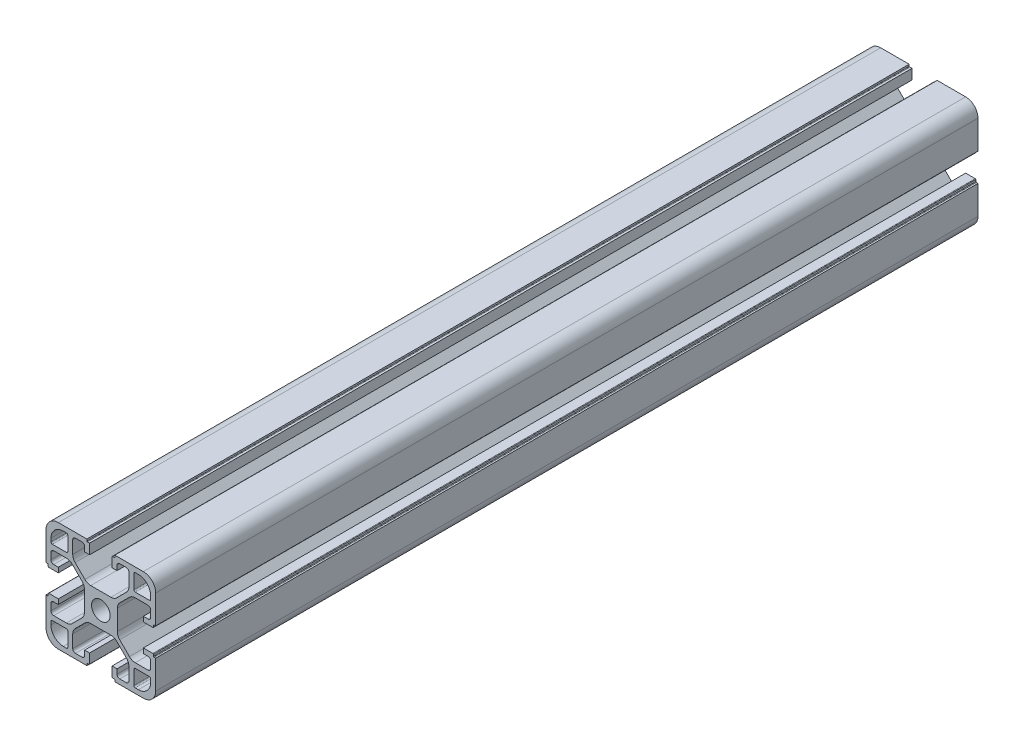
from build123d import *

# Parameters (mm, degrees)
BOSS_EXTRUDE1_DEPTH = 300


with BuildPart() as part:
    # Sketch1 → Boss-Extrude1 (new body)
    with BuildSketch(Plane.XY):
        with BuildLine():
            Line((84.170223908, 31.720417041), (84.170223908, 42.120417041))
            Line((84.170223908, 42.120417041), (83.570223908, 42.120417041))
            ThreePointArc((83.570223908, 42.120417041), (83.428802552, 42.178995685), (83.370223908, 42.320417041))
            Line((83.370223908, 42.320417041), (83.370223908, 42.920417041))
            ThreePointArc((83.370223908, 42.920417041), (83.311645264, 43.061838398), (83.170223908, 43.120417041))
            Line((83.170223908, 43.120417041), (79.670223908, 43.120417041))
            Line((79.670223908, 43.120417041), (79.670223908, 41.320417041))
            Line((79.670223908, 41.320417041), (81.370223908, 41.320417041))
            ThreePointArc((81.370223908, 41.320417041), (82.077330689, 41.027523823), (82.370223908, 40.320417041))
            Line((82.370223908, 40.320417041), (82.370223908, 37.970417041))
            ThreePointArc((82.370223908, 37.970417041), (82.077330689, 37.26331026), (81.370223908, 36.970417041))
            Line((81.370223908, 36.970417041), (76.723524767, 36.970417041))
            ThreePointArc((76.723524767, 36.970417041), (75.57547447, 37.198778444), (74.602204423, 37.849096698))
            Line((74.602204423, 37.849096698), (71.048903564, 41.402397557))
            ThreePointArc((71.048903564, 41.402397557), (70.39858531, 42.375667603), (70.170223908, 43.5237179))
            Line((70.170223908, 43.5237179), (70.170223908, 50.917116183))
            ThreePointArc((70.170223908, 50.917116183), (70.39858531, 52.06516648), (71.048903564, 53.038436526))
            Line((71.048903564, 53.038436526), (74.602204423, 56.591737385))
            ThreePointArc((74.602204423, 56.591737385), (75.57547447, 57.242055639), (76.723524767, 57.470417041))
            Line((76.723524767, 57.470417041), (81.370223908, 57.470417041))
            ThreePointArc((81.370223908, 57.470417041), (82.077330689, 57.177523823), (82.370223908, 56.470417041))
            Line((82.370223908, 56.470417041), (82.370223908, 54.120417041))
            ThreePointArc((82.370223908, 54.120417041), (82.077330689, 53.41331026), (81.370223908, 53.120417041))
            Line((81.370223908, 53.120417041), (79.670223908, 53.120417041))
            Line((79.670223908, 53.120417041), (79.670223908, 51.320417041))
            Line((79.670223908, 51.320417041), (83.170223908, 51.320417041))
            ThreePointArc((83.170223908, 51.320417041), (83.311645264, 51.378995685), (83.370223908, 51.520417041))
            Line((83.370223908, 51.520417041), (83.370223908, 52.120417041))
            ThreePointArc((83.370223908, 52.120417041), (83.428802552, 52.261838398), (83.570223908, 52.320417041))
            Line((83.570223908, 52.320417041), (84.170223908, 52.320417041))
            Line((84.170223908, 52.320417041), (84.170223908, 62.720417041))
            ThreePointArc((84.170223908, 62.720417041), (82.852204423, 65.902397557), (79.670223908, 67.220417041))
            Line((79.670223908, 67.220417041), (69.270223908, 67.220417041))
            Line((69.270223908, 67.220417041), (69.270223908, 66.420417041))
            Line((69.270223908, 66.420417041), (68.470223908, 66.420417041))
            ThreePointArc((68.470223908, 66.420417041), (68.328802552, 66.361838398), (68.270223908, 66.220417041))
            Line((68.270223908, 66.220417041), (68.270223908, 62.720417041))
            Line((68.270223908, 62.720417041), (70.070223908, 62.720417041))
            Line((70.070223908, 62.720417041), (70.070223908, 64.420417041))
            ThreePointArc((70.070223908, 64.420417041), (70.363117127, 65.127523823), (71.070223908, 65.420417041))
            Line((71.070223908, 65.420417041), (73.420223908, 65.420417041))
            ThreePointArc((73.420223908, 65.420417041), (74.127330689, 65.127523823), (74.420223908, 64.420417041))
            Line((74.420223908, 64.420417041), (74.420223908, 59.7737179))
            ThreePointArc((74.420223908, 59.7737179), (74.191862505, 58.625667603), (73.541544251, 57.652397557))
            Line((73.541544251, 57.652397557), (69.988243393, 54.099096698))
            ThreePointArc((69.988243393, 54.099096698), (69.014973346, 53.448778444), (67.866923049, 53.220417041))
            Line((67.866923049, 53.220417041), (60.473524767, 53.220417041))
            ThreePointArc((60.473524767, 53.220417041), (59.32547447, 53.448778444), (58.352204423, 54.099096698))
            Line((58.352204423, 54.099096698), (54.798903564, 57.652397557))
            ThreePointArc((54.798903564, 57.652397557), (54.14858531, 58.625667603), (53.920223908, 59.7737179))
            Line((53.920223908, 59.7737179), (53.920223908, 64.420417041))
            ThreePointArc((53.920223908, 64.420417041), (54.213117127, 65.127523823), (54.920223908, 65.420417041))
            Line((54.920223908, 65.420417041), (57.270223908, 65.420417041))
            ThreePointArc((57.270223908, 65.420417041), (57.977330689, 65.127523823), (58.270223908, 64.420417041))
            Line((58.270223908, 64.420417041), (58.270223908, 62.720417041))
            Line((58.270223908, 62.720417041), (60.070223908, 62.720417041))
            Line((60.070223908, 62.720417041), (60.070223908, 66.420417041))
            Line((60.070223908, 66.420417041), (59.270223908, 66.420417041))
            ThreePointArc((59.270223908, 66.420417041), (59.128802552, 66.478995685), (59.070223908, 66.620417041))
            Line((59.070223908, 66.620417041), (59.070223908, 67.220417041))
            Line((59.070223908, 67.220417041), (48.670223908, 67.220417041))
            ThreePointArc((48.670223908, 67.220417041), (45.488243393, 65.902397557), (44.170223908, 62.720417041))
            Line((44.170223908, 62.720417041), (44.170223908, 52.320417041))
            Line((44.170223908, 52.320417041), (44.770223908, 52.320417041))
            ThreePointArc((44.770223908, 52.320417041), (44.911645264, 52.261838398), (44.970223908, 52.120417041))
            Line((44.970223908, 52.120417041), (44.970223908, 51.520417041))
            ThreePointArc((44.970223908, 51.520417041), (45.028802552, 51.378995685), (45.170223908, 51.320417041))
            Line((45.170223908, 51.320417041), (48.670223908, 51.320417041))
            Line((48.670223908, 51.320417041), (48.670223908, 53.120417041))
            Line((48.670223908, 53.120417041), (46.970223908, 53.120417041))
            ThreePointArc((46.970223908, 53.120417041), (46.263117127, 53.41331026), (45.970223908, 54.120417041))
            Line((45.970223908, 54.120417041), (45.970223908, 56.470417041))
            ThreePointArc((45.970223908, 56.470417041), (46.263117127, 57.177523823), (46.970223908, 57.470417041))
            Line((46.970223908, 57.470417041), (51.616923049, 57.470417041))
            ThreePointArc((51.616923049, 57.470417041), (52.764973346, 57.242055639), (53.738243393, 56.591737385))
            Line((53.738243393, 56.591737385), (57.291544251, 53.038436526))
            ThreePointArc((57.291544251, 53.038436526), (57.941862505, 52.06516648), (58.170223908, 50.917116183))
            Line((58.170223908, 50.917116183), (58.170223908, 43.5237179))
            ThreePointArc((58.170223908, 43.5237179), (57.941862505, 42.375667603), (57.291544251, 41.402397557))
            Line((57.291544251, 41.402397557), (53.738243393, 37.849096698))
            ThreePointArc((53.738243393, 37.849096698), (52.764973346, 37.198778444), (51.616923049, 36.970417041))
            Line((51.616923049, 36.970417041), (46.970223908, 36.970417041))
            ThreePointArc((46.970223908, 36.970417041), (46.263117127, 37.26331026), (45.970223908, 37.970417041))
            Line((45.970223908, 37.970417041), (45.970223908, 40.320417041))
            ThreePointArc((45.970223908, 40.320417041), (46.263117127, 41.027523823), (46.970223908, 41.320417041))
            Line((46.970223908, 41.320417041), (48.670223908, 41.320417041))
            Line((48.670223908, 41.320417041), (48.670223908, 43.120417041))
            Line((48.670223908, 43.120417041), (45.170223908, 43.120417041))
            ThreePointArc((45.170223908, 43.120417041), (45.028802552, 43.061838398), (44.970223908, 42.920417041))
            Line((44.970223908, 42.920417041), (44.970223908, 42.320417041))
            ThreePointArc((44.970223908, 42.320417041), (44.911645264, 42.178995685), (44.770223908, 42.120417041))
            Line((44.770223908, 42.120417041), (44.170223908, 42.120417041))
            Line((44.170223908, 42.120417041), (44.170223908, 31.720417041))
            ThreePointArc((44.170223908, 31.720417041), (45.488243393, 28.538436526), (48.670223908, 27.220417041))
            Line((48.670223908, 27.220417041), (59.070223908, 27.220417041))
            Line((59.070223908, 27.220417041), (59.070223908, 27.820417041))
            ThreePointArc((59.070223908, 27.820417041), (59.128802552, 27.961838398), (59.270223908, 28.020417041))
            Line((59.270223908, 28.020417041), (59.870223908, 28.020417041))
            ThreePointArc((59.870223908, 28.020417041), (60.011645264, 28.078995685), (60.070223908, 28.220417041))
            Line((60.070223908, 28.220417041), (60.070223908, 31.720417041))
            Line((60.070223908, 31.720417041), (58.270223908, 31.720417041))
            Line((58.270223908, 31.720417041), (58.270223908, 30.020417041))
            ThreePointArc((58.270223908, 30.020417041), (57.977330689, 29.31331026), (57.270223908, 29.020417041))
            Line((57.270223908, 29.020417041), (54.920223908, 29.020417041))
            ThreePointArc((54.920223908, 29.020417041), (54.213117127, 29.31331026), (53.920223908, 30.020417041))
            Line((53.920223908, 30.020417041), (53.920223908, 34.667116183))
            ThreePointArc((53.920223908, 34.667116183), (54.14858531, 35.81516648), (54.798903564, 36.788436526))
            Line((54.798903564, 36.788436526), (58.352204423, 40.341737385))
            ThreePointArc((58.352204423, 40.341737385), (59.32547447, 40.992055639), (60.473524767, 41.220417041))
            Line((60.473524767, 41.220417041), (67.866923049, 41.220417041))
            ThreePointArc((67.866923049, 41.220417041), (69.014973346, 40.992055639), (69.988243393, 40.341737385))
            Line((69.988243393, 40.341737385), (73.541544251, 36.788436526))
            ThreePointArc((73.541544251, 36.788436526), (74.191862505, 35.81516648), (74.420223908, 34.667116183))
            Line((74.420223908, 34.667116183), (74.420223908, 30.020417041))
            ThreePointArc((74.420223908, 30.020417041), (74.127330689, 29.31331026), (73.420223908, 29.020417041))
            Line((73.420223908, 29.020417041), (71.070223908, 29.020417041))
            ThreePointArc((71.070223908, 29.020417041), (70.363117127, 29.31331026), (70.070223908, 30.020417041))
            Line((70.070223908, 30.020417041), (70.070223908, 31.720417041))
            Line((70.070223908, 31.720417041), (68.270223908, 31.720417041))
            Line((68.270223908, 31.720417041), (68.270223908, 28.220417041))
            ThreePointArc((68.270223908, 28.220417041), (68.328802552, 28.078995685), (68.470223908, 28.020417041))
            Line((68.470223908, 28.020417041), (69.070223908, 28.020417041))
            ThreePointArc((69.070223908, 28.020417041), (69.211645264, 27.961838398), (69.270223908, 27.820417041))
            Line((69.270223908, 27.820417041), (69.270223908, 27.220417041))
            Line((69.270223908, 27.220417041), (79.670223908, 27.220417041))
            ThreePointArc((79.670223908, 27.220417041), (82.852204423, 28.538436526), (84.170223908, 31.720417041))
        make_face()
        with BuildLine():
            Line((82.370223908, 34.670417041), (82.370223908, 33.520417041))
            ThreePointArc((82.370223908, 33.520417041), (81.052204423, 30.338436526), (77.870223908, 29.020417041))
            Line((77.870223908, 29.020417041), (76.720223908, 29.020417041))
            ThreePointArc((76.720223908, 29.020417041), (76.366670517, 29.166863651), (76.220223908, 29.520417041))
            Line((76.220223908, 29.520417041), (76.220223908, 34.670417041))
            ThreePointArc((76.220223908, 34.670417041), (76.366670517, 35.023970432), (76.720223908, 35.170417041))
            Line((76.720223908, 35.170417041), (81.870223908, 35.170417041))
            ThreePointArc((81.870223908, 35.170417041), (82.223777298, 35.023970432), (82.370223908, 34.670417041))
        make_face(mode=Mode.SUBTRACT)
        with BuildLine():
            Line((51.620223908, 29.020417041), (50.470223908, 29.020417041))
            ThreePointArc((50.470223908, 29.020417041), (47.288243393, 30.338436526), (45.970223908, 33.520417041))
            Line((45.970223908, 33.520417041), (45.970223908, 34.670417041))
            ThreePointArc((45.970223908, 34.670417041), (46.116670517, 35.023970432), (46.470223908, 35.170417041))
            Line((46.470223908, 35.170417041), (51.620223908, 35.170417041))
            ThreePointArc((51.620223908, 35.170417041), (51.973777298, 35.023970432), (52.120223908, 34.670417041))
            Line((52.120223908, 34.670417041), (52.120223908, 29.520417041))
            ThreePointArc((52.120223908, 29.520417041), (51.973777298, 29.166863651), (51.620223908, 29.020417041))
        make_face(mode=Mode.SUBTRACT)
        with BuildLine():
            Line((45.970223908, 59.770417041), (45.970223908, 60.920417041))
            ThreePointArc((45.970223908, 60.920417041), (47.288243393, 64.102397557), (50.470223908, 65.420417041))
            Line((50.470223908, 65.420417041), (51.620223908, 65.420417041))
            ThreePointArc((51.620223908, 65.420417041), (51.973777298, 65.273970432), (52.120223908, 64.920417041))
            Line((52.120223908, 64.920417041), (52.120223908, 59.770417041))
            ThreePointArc((52.120223908, 59.770417041), (51.973777298, 59.416863651), (51.620223908, 59.270417041))
            Line((51.620223908, 59.270417041), (46.470223908, 59.270417041))
            ThreePointArc((46.470223908, 59.270417041), (46.116670517, 59.416863651), (45.970223908, 59.770417041))
        make_face(mode=Mode.SUBTRACT)
        with BuildLine():
            Line((76.720223908, 65.420417041), (77.870223908, 65.420417041))
            ThreePointArc((77.870223908, 65.420417041), (81.052204423, 64.102397557), (82.370223908, 60.920417041))
            Line((82.370223908, 60.920417041), (82.370223908, 59.770417041))
            ThreePointArc((82.370223908, 59.770417041), (82.223777298, 59.416863651), (81.870223908, 59.270417041))
            Line((81.870223908, 59.270417041), (76.720223908, 59.270417041))
            ThreePointArc((76.720223908, 59.270417041), (76.366670517, 59.416863651), (76.220223908, 59.770417041))
            Line((76.220223908, 59.770417041), (76.220223908, 64.920417041))
            ThreePointArc((76.220223908, 64.920417041), (76.366670517, 65.273970432), (76.720223908, 65.420417041))
        make_face(mode=Mode.SUBTRACT)
        with BuildLine():
            ThreePointArc((60.770223908, 47.220417041), (64.170223908, 43.820417041), (67.570223908, 47.220417041))
            ThreePointArc((67.570223908, 47.220417041), (64.170223908, 50.620417041), (60.770223908, 47.220417041))
        make_face(mode=Mode.SUBTRACT)
    extrude(amount=BOSS_EXTRUDE1_DEPTH)


solid = part.part
